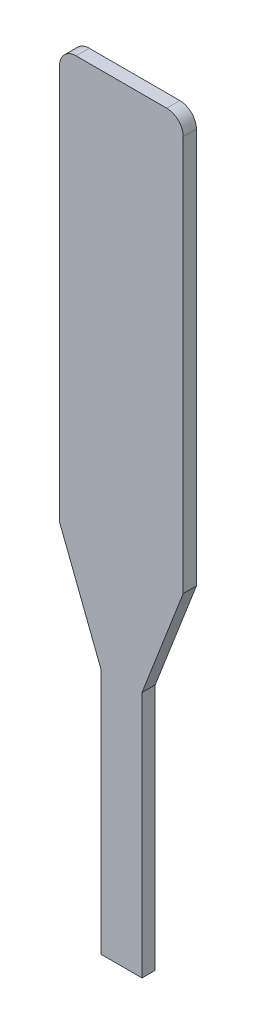
from build123d import *

# Parameters (mm, degrees)
BOSS_EXTRUDE1_DEPTH = 0.2032
FILLET2_R           = 0.254


with BuildPart() as part:
    # Sketch1 → Boss-Extrude1 (new body)
    with BuildSketch(Plane.XY):
        Polygon((-49.105346889, -47.930248144), (-47.200346889, -47.930248144), (-47.200346889, -54.280248144), (-47.835346889, -55.917821802), (-47.835346889, -59.727821802), (-48.470346889, -59.727821802), (-48.470346889, -55.917821802), (-49.105346889, -54.280248144), align=None)
    extrude(amount=BOSS_EXTRUDE1_DEPTH)

    # Fillet2
    fillet2_edges = [part.edges().sort_by_distance(p)[0] for p in [
        (-49.105346889, -47.930248144, 0.1016),
        (-47.200346889, -47.930248144, 0.1016),
    ]]
    fillet(fillet2_edges, radius=FILLET2_R)


solid = part.part
